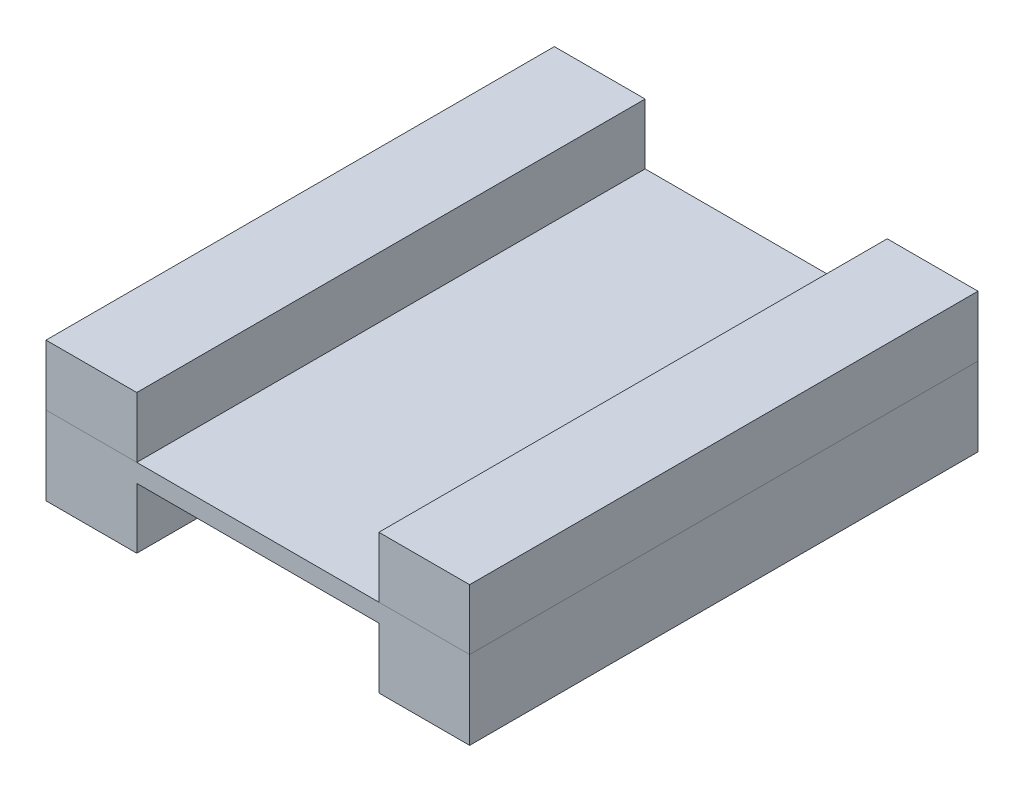
from build123d import *

# Parameters (mm, degrees)
SKETCH1_W             = 70
SKETCH1_H             = 84
BOSS_EXTRUDE1_DEPTH   = 3
SKETCH2_W             = 15
SKETCH2_H             = 84
BOSS_EXTRUDE2_DEPTH   = 10
BOSS_EXTRUDE2_2_DEPTH = 10


with BuildPart() as part:
    # Sketch1 → Boss-Extrude1 (new body)
    with BuildSketch(Plane(origin=(0, 0, 0), x_dir=(1, 0, 0), z_dir=(0, 1, 0))):
        Rectangle(SKETCH1_W, SKETCH1_H)
    extrude(amount=BOSS_EXTRUDE1_DEPTH)


with BuildPart() as body_2:
    # Sketch2 → Boss-Extrude2 (new body)
    with BuildSketch(Plane(origin=(0, 3, 0), x_dir=(1, 0, 0), z_dir=(0, 1, 0))):
        with Locations((-27.5, 0)):
            Rectangle(SKETCH2_W, SKETCH2_H)
    boss_extrude2 = extrude(amount=BOSS_EXTRUDE2_DEPTH)


with BuildPart() as body_3:
    # Sketch2 → Boss-Extrude2 2 (new body)
    with BuildSketch(Plane(origin=(0, 3, 0), x_dir=(1, 0, 0), z_dir=(0, 1, 0))):
        with Locations((27.5, 0)):
            Rectangle(SKETCH2_W, SKETCH2_H)
    boss_extrude2_2 = extrude(amount=BOSS_EXTRUDE2_2_DEPTH)


with BuildPart() as part_1:
    add(part.part)

    # Mirror3: Boss-Extrude2, Boss-Extrude2 2 across plane
    add(boss_extrude2.mirror(Plane(origin=(0, 1.5, 0), x_dir=(0, 0, 1), z_dir=(0, -1, 0))))
    add(boss_extrude2_2.mirror(Plane(origin=(0, 1.5, 0), x_dir=(0, 0, 1), z_dir=(0, -1, 0))))


solid = Compound([body_2.part, body_3.part, part_1.part])
